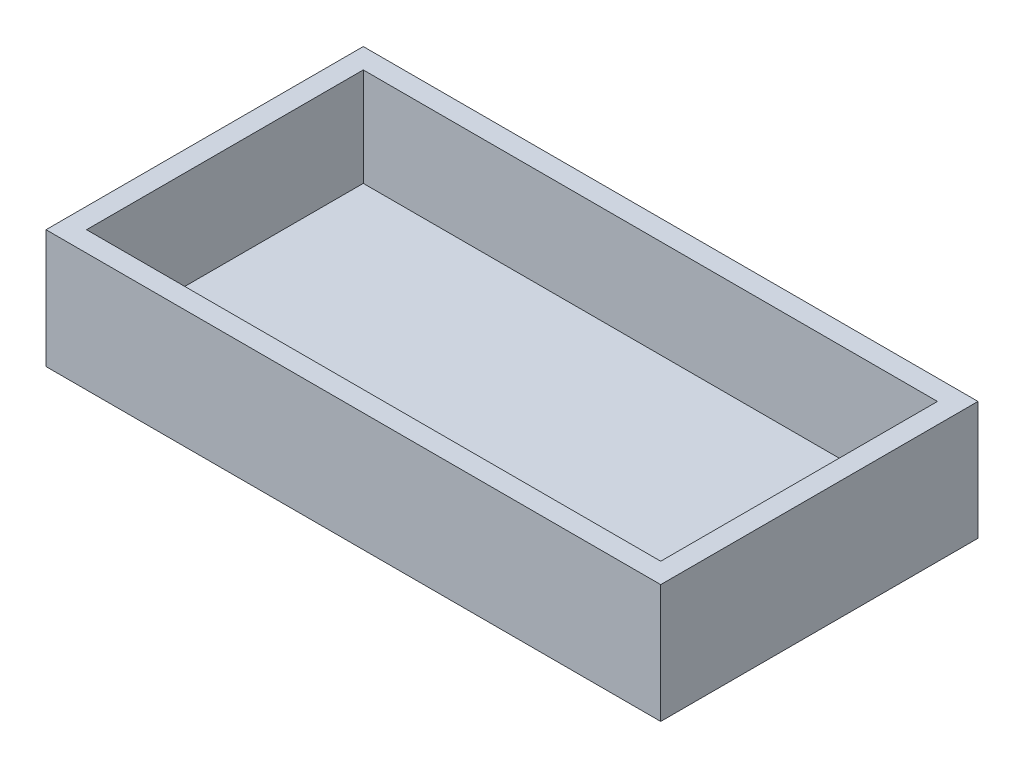
from build123d import *

# Parameters (mm, degrees)
SKETCH1_W           = 77.0636
SKETCH1_H           = 39.7764
BOSS_EXTRUDE1_DEPTH = 14.859
SHELL1_T            = -2.54


with BuildPart() as part:
    # Sketch1 → Boss-Extrude1 (new body)
    with BuildSketch(Plane(origin=(0, 0, 0), x_dir=(1, 0, 0), z_dir=(0, 1, 0))):
        with Locations((38.5318, 19.8882)):
            Rectangle(SKETCH1_W, SKETCH1_H)
    extrude(amount=BOSS_EXTRUDE1_DEPTH)

    # Shell1
    shell1_openings = [part.faces().sort_by_distance(p)[0] for p in [
        (38.5318, 14.859, -19.8882),
    ]]
    offset(amount=SHELL1_T, openings=shell1_openings, kind=Kind.INTERSECTION)


solid = part.part
